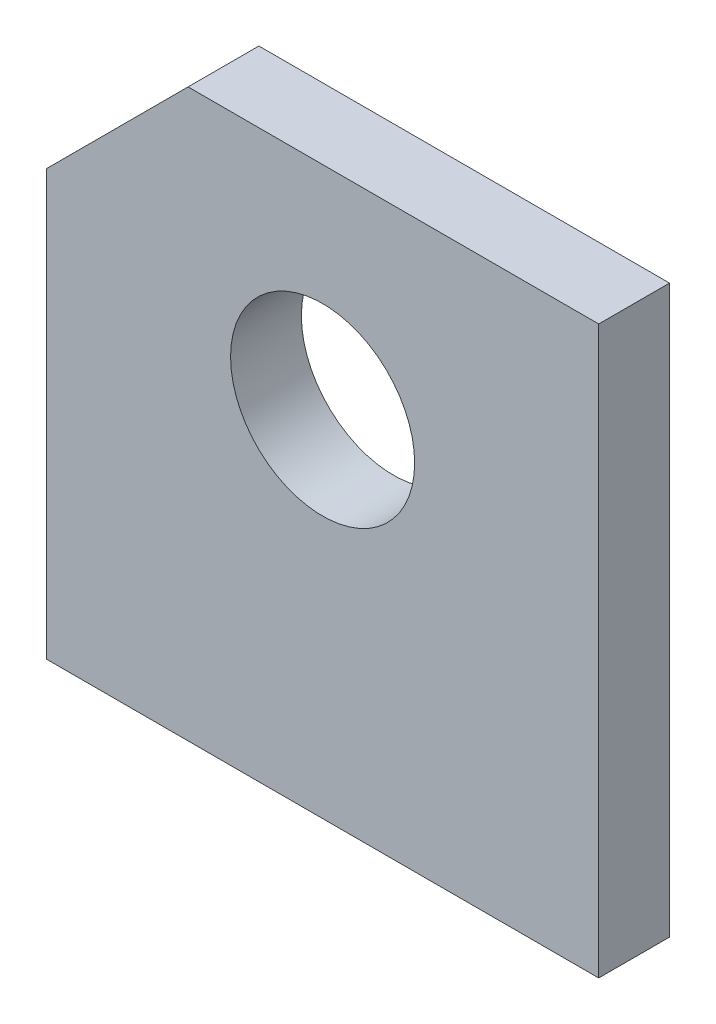
from build123d import *

# Parameters (mm, degrees)
SKETCH1_R           = 3.302
BOSS_EXTRUDE1_DEPTH = 2.54


with BuildPart() as part:
    # Sketch1 → Boss-Extrude1 (new body)
    with BuildSketch(Plane.XY):
        Polygon((0, 15.24), (5.08, 20.32), (19.812, 20.32), (19.812, 0), (0, 0), align=None)
        with Locations((9.906, 12.7)):
            Circle(SKETCH1_R, mode=Mode.SUBTRACT)
    extrude(amount=BOSS_EXTRUDE1_DEPTH)


solid = part.part
